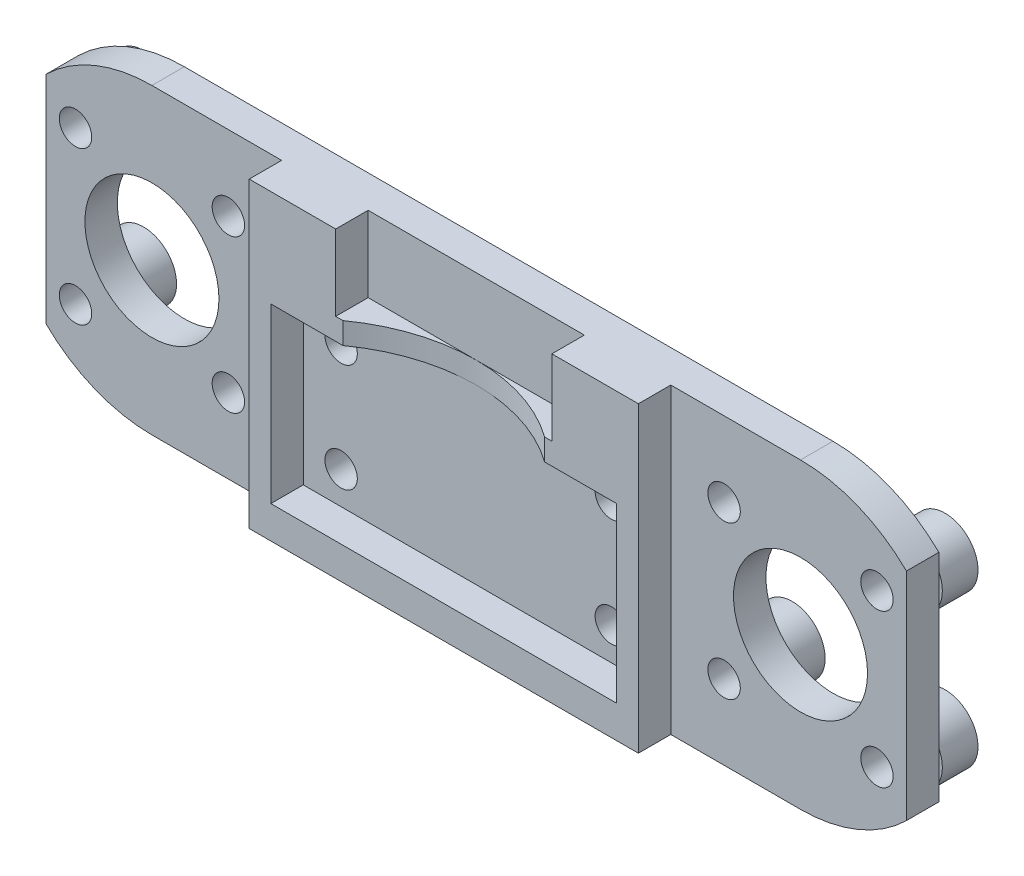
from build123d import *

# Parameters (mm, degrees)
SKETCH1_R              = 6.2
MAIN_DEPTH             = 1.5
SKETCH2_W              = 32
SKETCH2_H              = 16
FRAMEWORK_DEPTH        = 3
SKETCH3_R              = 1.5
FIXHOLE_DEPTH          = 7
HOLEPATTERN_COUNT      = 2
HOLEPATTERN_PITCH      = 25
HOLEPATTERN_COUNT_DIR2 = 2
HOLEPATTERN_PITCH_DIR2 = 10
SKETCH4_R              = 3.05
SKETCH4_R_2            = 1.5
FORLMK6UU_DEPTH        = 3.3
SKETCH5_R              = 1.5
CUT_EXTRUDE1_DEPTH     = 7.3
SKETCH6_R              = 16
CUT_EXTRUDE2_DEPTH     = 2


with BuildPart() as part:
    # Sketch1 → Main (new body, symmetric)
    with BuildSketch(Plane.XY):
        with BuildLine():
            Line((-39.8, 9.9979998), (-39.8, -9.9979998))
            ThreePointArc((-39.8, -9.9979998), (-35.292825465, -12.96094127), (-30, -14))
            Line((-30, -14), (30, -14))
            ThreePointArc((30, -14), (35.292825465, -12.96094127), (39.8, -9.9979998))
            Line((39.8, -9.9979998), (39.8, 9.9979998))
            ThreePointArc((39.8, 9.9979998), (35.292825465, 12.96094127), (30, 14))
            Line((30, 14), (-30, 14))
            ThreePointArc((-30, 14), (-35.292825465, 12.96094127), (-39.8, 9.9979998))
        make_face()
        with Locations((-30, 0)):
            Circle(SKETCH1_R, mode=Mode.SUBTRACT)
        with Locations((30, 0)):
            Circle(SKETCH1_R, mode=Mode.SUBTRACT)
    extrude(amount=MAIN_DEPTH, both=True)

    # Sketch2 → Framework (add)
    with BuildSketch(Plane(origin=(0, 0, 1.5), x_dir=(-1, 0, 0), z_dir=(0, 0, -1))):
        Polygon((18, 14), (10, 14), (10, 7), (-10, 7), (-10, 14), (-18, 14), (-18, -14), (18, -14), align=None)
        with Locations((0, -3)):
            Rectangle(SKETCH2_W, SKETCH2_H, mode=Mode.SUBTRACT)
    extrude(amount=-FRAMEWORK_DEPTH)

    # Sketch3 → FixHole (cut, through all)
    with BuildSketch(Plane(origin=(0, 0, -1.5), x_dir=(-1, 0, 0), z_dir=(0, 0, -1))):
        with Locations((12.5, -8)):
            Circle(SKETCH3_R)
    fixhole = extrude(amount=-FIXHOLE_DEPTH, mode=Mode.SUBTRACT)

    # HolePattern: FixHole 2 × 2
    with Locations(*[(i * HOLEPATTERN_PITCH, j * HOLEPATTERN_PITCH_DIR2, 0) for i in range(HOLEPATTERN_COUNT) for j in range(HOLEPATTERN_COUNT_DIR2) if (i, j) != (0, 0)]):
        add(fixhole, mode=Mode.SUBTRACT)

    # Sketch4 → ForLMK6UU (add)
    with BuildSketch(Plane.XY.offset(-1.5)):
        with Locations((-37.071067812, 7.071067812)):
            Circle(SKETCH4_R)
        with Locations((-37.071067812, 7.071067812)):
            Circle(SKETCH4_R_2, mode=Mode.SUBTRACT)
        with Locations((-22.928932188, -7.071067812)):
            Circle(SKETCH4_R)
        with Locations((-22.928932188, -7.071067812)):
            Circle(SKETCH4_R_2, mode=Mode.SUBTRACT)
        with Locations((-22.928932188, 7.071067812)):
            Circle(SKETCH4_R)
        with Locations((-22.928932188, 7.071067812)):
            Circle(SKETCH4_R_2, mode=Mode.SUBTRACT)
        with Locations((-37.071067812, -7.071067812)):
            Circle(SKETCH4_R)
        with Locations((-37.071067812, -7.071067812)):
            Circle(SKETCH4_R_2, mode=Mode.SUBTRACT)
    forlmk6uu = extrude(amount=-FORLMK6UU_DEPTH)

    # Sketch5 → Cut-Extrude1 (cut, through all)
    with BuildSketch(Plane.XY.offset(1.5)):
        with Locations((-37.071067812, 7.071067812)):
            Circle(SKETCH5_R)
        with Locations((-22.928932188, 7.071067812)):
            Circle(SKETCH5_R)
        with Locations((-37.071067812, -7.071067812)):
            Circle(SKETCH5_R)
        with Locations((-22.928932188, -7.071067812)):
            Circle(SKETCH5_R)
    cut_extrude1 = extrude(amount=-CUT_EXTRUDE1_DEPTH, mode=Mode.SUBTRACT)

    # Mirror1: ForLMK6UU, Cut-Extrude1 across plane
    add(forlmk6uu.mirror(Plane(origin=(0, 0, 0), x_dir=(0, 0, 1), z_dir=(1, 0, 0))))
    add(cut_extrude1.mirror(Plane(origin=(0, 0, 0), x_dir=(0, 0, 1), z_dir=(1, 0, 0))), mode=Mode.SUBTRACT)

    # Sketch6 → Cut-Extrude2 (cut)
    with BuildSketch(Plane(origin=(0, 7, 0), x_dir=(1, 0, 0), z_dir=(0, 1, 0))):
        with Locations((0, -17.5)):
            Circle(SKETCH6_R)
    extrude(amount=-CUT_EXTRUDE2_DEPTH, mode=Mode.SUBTRACT)


solid = part.part
